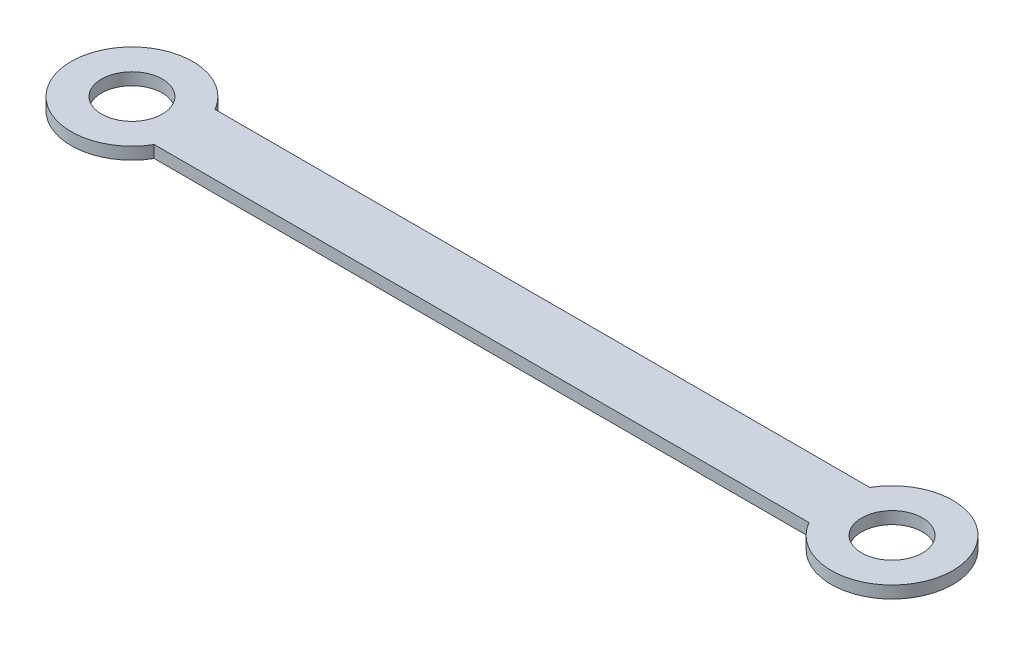
from build123d import *

# Parameters (mm, degrees)
SKETCH_5_R      = 5
EXTRUDE_1_DEPTH = 2


with BuildPart() as part:
    # 草圖5 → 填料-伸長1 (new body)
    with BuildSketch(Plane(origin=(0, 0, 0), x_dir=(1, 0, 0), z_dir=(0, 1, 0))):
        with BuildLine():
            Line((8.660254038, -5), (116.339745962, -5))
            ThreePointArc((116.339745962, -5), (135, 0), (116.339745962, 5))
            Line((116.339745962, 5), (8.660254038, 5))
            ThreePointArc((8.660254038, 5), (-10, 0), (8.660254038, -5))
        make_face()
        Circle(SKETCH_5_R, mode=Mode.SUBTRACT)
        with Locations((125, 0)):
            Circle(SKETCH_5_R, mode=Mode.SUBTRACT)
    extrude(amount=EXTRUDE_1_DEPTH)


solid = part.part
